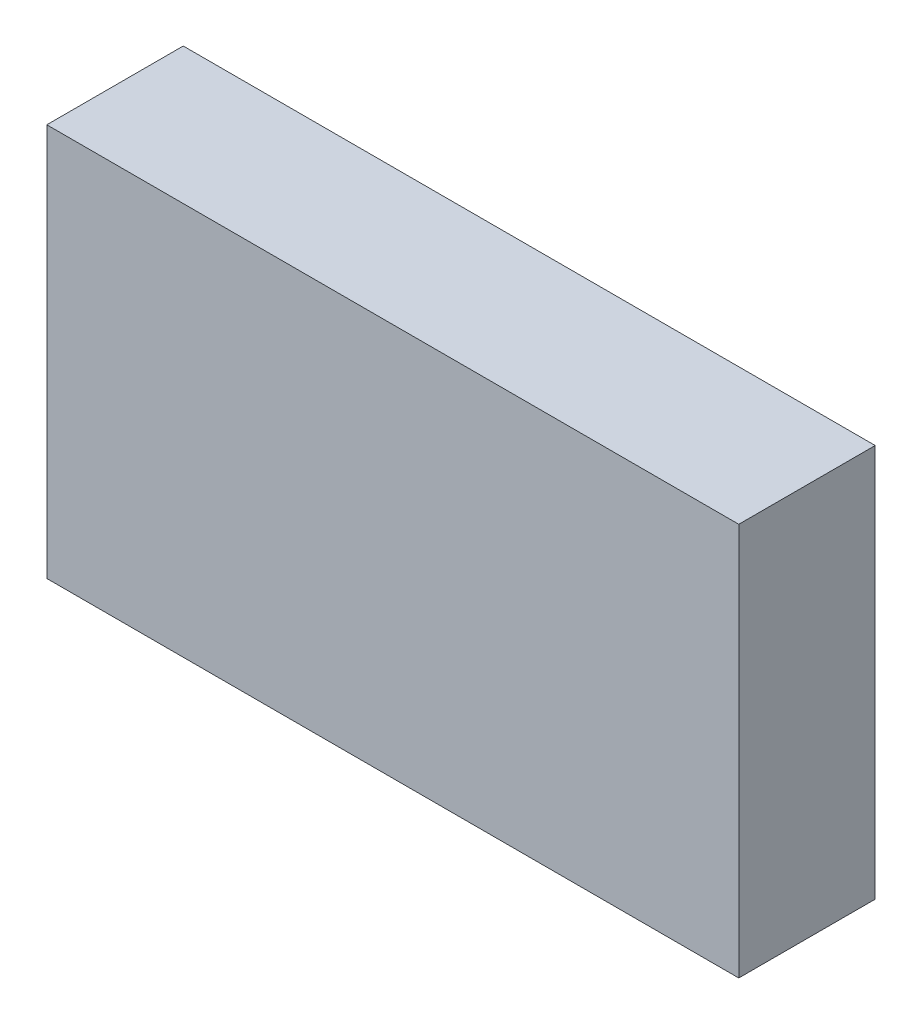
from build123d import *

# Parameters (mm, degrees)
SKETCH1_W           = 126.79
SKETCH1_H           = 72
BOSS_EXTRUDE1_DEPTH = 25


with BuildPart() as part:
    # Sketch1 → Boss-Extrude1 (new body)
    with BuildSketch(Plane.XY):
        Rectangle(SKETCH1_W, SKETCH1_H)
    extrude(amount=BOSS_EXTRUDE1_DEPTH)


solid = part.part
